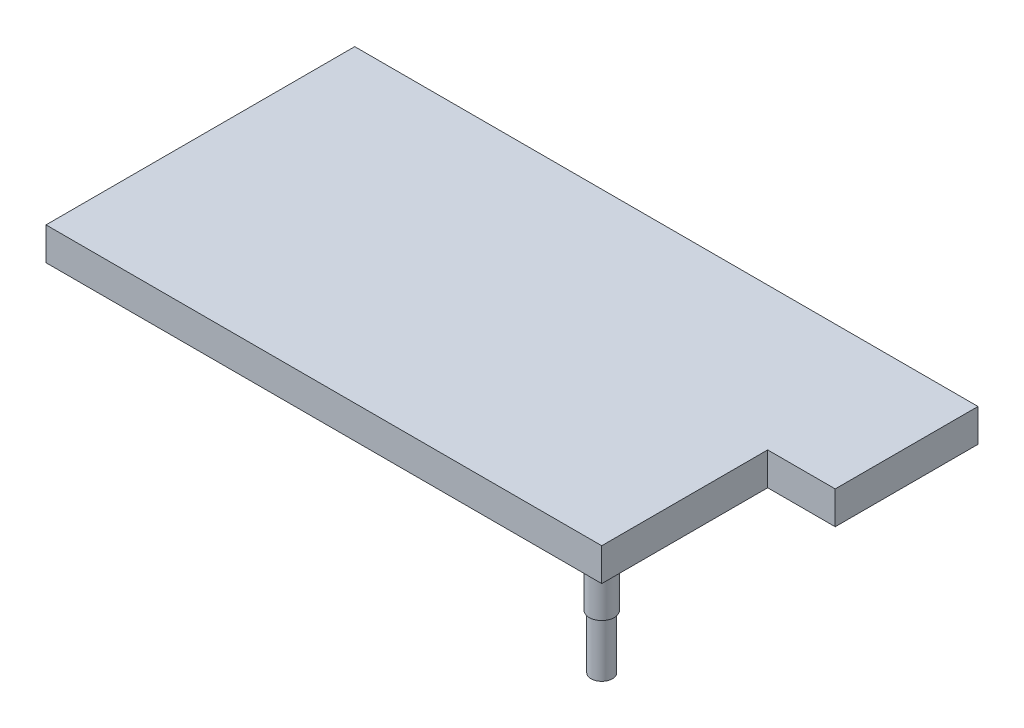
from build123d import *

# Parameters (mm, degrees)
SKETCH1_W           = 914.4
SKETCH1_H           = 508
BOSS_EXTRUDE1_DEPTH = 1.5875
SKETCH2_W           = 914.4
SKETCH2_H           = 508
SKETCH2_W_2         = 812.8
SKETCH2_H_2         = 406.4
BOSS_EXTRUDE2_DEPTH = 50.8
SKETCH3_R           = 17.4625
BOSS_EXTRUDE3_DEPTH = 152.4
SKETCH4_R           = 20.6375
SKETCH4_R_2         = 17.4625
BOSS_EXTRUDE4_DEPTH = 63.5
SKETCH5_W           = 234.95
SKETCH5_H           = 53.975
BOSS_EXTRUDE5_DEPTH = 111.125


with BuildPart() as part:
    # Sketch1 → Boss-Extrude1 (new body, symmetric)
    with BuildSketch(Plane(origin=(0, 0, 0), x_dir=(1, 0, 0), z_dir=(0, 1, 0))):
        with Locations((-457.2, 254)):
            Rectangle(SKETCH1_W, SKETCH1_H)
    extrude(amount=BOSS_EXTRUDE1_DEPTH, both=True)

    # Sketch2 → Boss-Extrude2 (add)
    with BuildSketch(Plane.XZ.offset(1.5875)):
        with Locations((-457.2, -254)):
            Rectangle(SKETCH2_W, SKETCH2_H)
        with Locations((-457.2, -254)):
            Rectangle(SKETCH2_W_2, SKETCH2_H_2, mode=Mode.SUBTRACT)
    extrude(amount=BOSS_EXTRUDE2_DEPTH)

    # Sketch3 → Boss-Extrude3 (add)
    with BuildSketch(Plane.XZ.offset(52.3875)):
        with Locations(Location((-25.4, -25.4, 0), (0, 0, 270))):  # turned: the seam where the file's is
            Circle(SKETCH3_R)
    extrude(amount=BOSS_EXTRUDE3_DEPTH)

    # Sketch5 → Boss-Extrude5 (add)
    with BuildSketch(Plane(origin=(0, 0, 0), x_dir=(0, 0, -1), z_dir=(1, 0, 0))):
        with Locations((390.525, -25.4)):
            Rectangle(SKETCH5_W, SKETCH5_H)
    extrude(amount=BOSS_EXTRUDE5_DEPTH)


with BuildPart() as body_2:
    # Sketch4 → Boss-Extrude4 (new body)
    with BuildSketch(Plane.XZ.offset(52.3875)):
        with Locations(Location((-25.4, -25.4, 0), (0, 0, 270))):  # turned: the seam where the file's is
            Circle(SKETCH4_R)
        with Locations(Location((-25.4, -25.4, 0), (0, 0, 270))):  # turned: the seam where the file's is
            Circle(SKETCH4_R_2, mode=Mode.SUBTRACT)
    extrude(amount=BOSS_EXTRUDE4_DEPTH)


solid = Compound([part.part, body_2.part])
